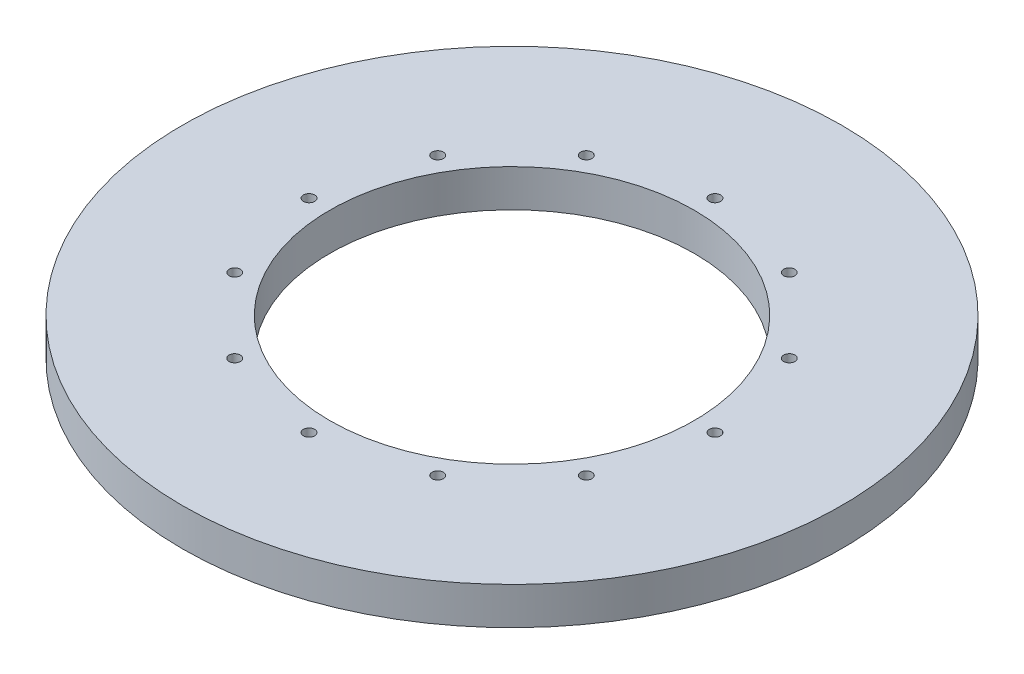
from build123d import *

# Parameters (mm, degrees)
SKETCH1_W           = 127.635
SKETCH1_H           = 127.635
BOSS_EXTRUDE1_DEPTH = 9.525
SKETCH12_R          = 83.82
BOSS_EXTRUDE2_DEPTH = 9.525
SKETCH13_R          = 104.928492752
SKETCH13_R_2        = 83.82
CUT_EXTRUDE4_DEPTH  = 9.525
SKETCH5_R           = 46.355
CUT_EXTRUDE1_DEPTH  = 9.525
SKETCH11_R          = 1.4351
CUT_EXTRUDE3_DEPTH  = 10.525
CIRPATTERN1_COUNT   = 12


with BuildPart() as part:
    # Sketch1 → Boss-Extrude1 (new body)
    with BuildSketch(Plane(origin=(0, 0, 0), x_dir=(1, 0, 0), z_dir=(0, 1, 0))):
        with Locations((63.8175, 63.8175)):
            Rectangle(SKETCH1_W, SKETCH1_H)
    extrude(amount=BOSS_EXTRUDE1_DEPTH)

    # Sketch12 → Boss-Extrude2 (add)
    with BuildSketch(Plane.XZ):
        with Locations((63.8175, -63.8175)):
            Circle(SKETCH12_R)
    extrude(amount=-BOSS_EXTRUDE2_DEPTH)

    # Sketch13 → Cut-Extrude4 (cut)
    with BuildSketch(Plane(origin=(0, 0, 0), x_dir=(-1, 0, 0), z_dir=(0, -1, 0))):
        with Locations((-63.8175, 63.8175)):
            Circle(SKETCH13_R)
        with Locations((-63.8175, 63.8175)):
            Circle(SKETCH13_R_2, mode=Mode.SUBTRACT)
    extrude(amount=-CUT_EXTRUDE4_DEPTH, mode=Mode.SUBTRACT)

    # Sketch5 → Cut-Extrude1 (cut)
    with BuildSketch(Plane(origin=(0, 9.525, 0), x_dir=(1, 0, 0), z_dir=(0, 1, 0))):
        with Locations((63.8175, 63.8175)):
            Circle(SKETCH5_R)
    extrude(amount=-CUT_EXTRUDE1_DEPTH, mode=Mode.SUBTRACT)

    # Sketch11 → Cut-Extrude3 (cut, through all)
    with BuildSketch(Plane(origin=(0, 9.525, 0), x_dir=(1, 0, 0), z_dir=(0, 1, 0))):
        with Locations((63.8175, 115.443)):
            Circle(SKETCH11_R)
    cut_extrude3 = extrude(amount=-CUT_EXTRUDE3_DEPTH, mode=Mode.SUBTRACT)

    # CirPattern1: Cut-Extrude3 ×12 about axis
    cirpattern1_axis = Axis((63.8175, 0, -63.8175), (0, 1, 0))
    for i in range(1, CIRPATTERN1_COUNT):
        add(cut_extrude3.rotate(cirpattern1_axis, i * 360 / CIRPATTERN1_COUNT), mode=Mode.SUBTRACT)


solid = part.part
